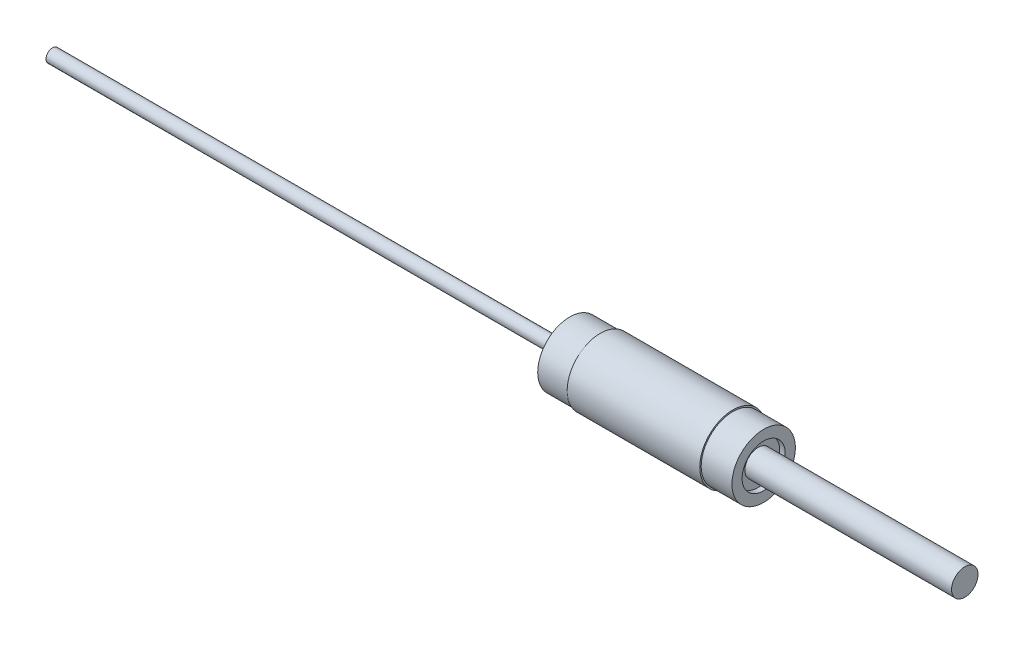
from build123d import *


with BuildPart() as part:
    # Sketch2 → Revolve1 (revolve)
    with BuildSketch(Plane.XY):
        Polygon((0, 1.59), (-126, 1.59), (-126, 0), (96.25, 0), (96.25, 3.225), (45.9, 3.225), (45.9, 3.375), (45.9, 5.25), (47.25, 5.25), (47.25, 7.725), (39.75, 7.725), (39.75, 8.075), (7.45, 8.075), (7.45, 7.8), (0, 7.8), (0, 3.35), align=None)
    revolve(axis=Axis((-88.99, 0, 0), (1, 0, 0)))


solid = part.part
